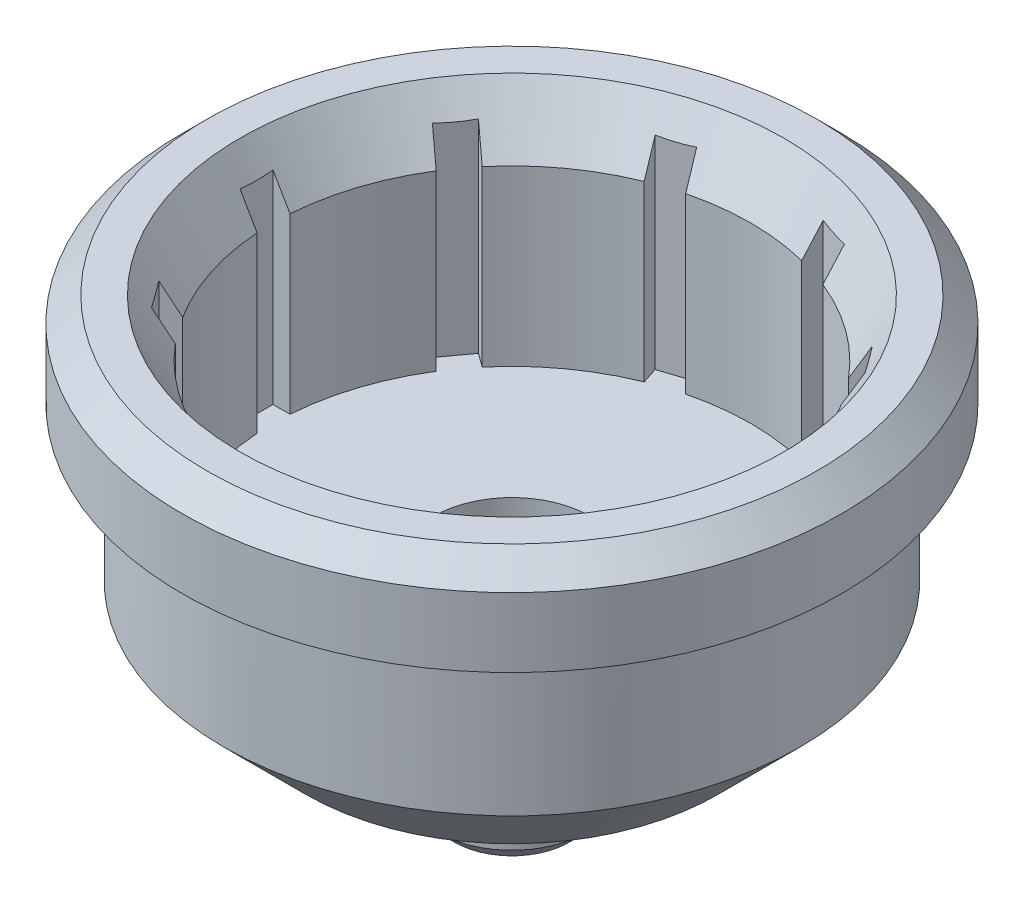
from build123d import *

# Parameters (mm, degrees)
CHAMFER1_SIZE      = 2
CHAMFER1_SIZE2     = 3.464101615
CHAMFER2_SIZE      = 1.5
SKETCH2_W          = 31
SKETCH2_H          = 2
CUT_EXTRUDE1_DEPTH = 15
CIRPATTERN1_COUNT  = 10
CHAMFER3_SIZE      = 5
CHAMFER4_SIZE      = 1


with BuildPart() as part:
    # Sketch1 → Revolve1 (revolve)
    with BuildSketch(Plane.XY):
        Polygon((-2.5, 0), (-2.5, 9), (-4.75, 9), (-4.75, 13), (-14.5, 13), (-14.5, 27), (-20, 27), (-20, 21.3), (-17.5, 21.3), (-17.5, 7), (-6.5, 7), (-6.5, 6), (-4.5, 6), (-4.5, 0), align=None)
    revolve(axis=Axis((0, 0, 0), (0, 1, 0)))

    # Chamfer1
    chamfer1_edges = [part.edges().sort_by_distance(p)[0] for p in [
        (14.5, 27, 0),
    ]]
    chamfer1_side = [part.faces().sort_by_distance(p)[0] for p in [
        (15.065685425, 27, 0),
    ]]
    chamfer(chamfer1_edges, length=CHAMFER1_SIZE, length2=CHAMFER1_SIZE2, reference=chamfer1_side[0])

    # Chamfer2
    chamfer2_edges = [part.edges().sort_by_distance(p)[0] for p in [
        (20, 27, 0),
    ]]
    chamfer(chamfer2_edges, length=CHAMFER2_SIZE)

    # Sketch2 → Cut-Extrude1 (cut, through all)
    with BuildSketch(Plane(origin=(0, 13, 0), x_dir=(1, 0, 0), z_dir=(0, 1, 0))):
        Rectangle(SKETCH2_W, SKETCH2_H)
    cut_extrude1 = extrude(amount=CUT_EXTRUDE1_DEPTH, mode=Mode.SUBTRACT)

    # CirPattern1: Cut-Extrude1 ×10 about axis
    cirpattern1_axis = Axis((0, 0, 0), (0, 1, 0))
    for i in range(1, CIRPATTERN1_COUNT):
        add(cut_extrude1.rotate(cirpattern1_axis, i * 360 / CIRPATTERN1_COUNT), mode=Mode.SUBTRACT)

    # Chamfer3
    chamfer3_edges = [part.edges().sort_by_distance(p)[0] for p in [
        (17.5, 7, 0),
    ]]
    chamfer(chamfer3_edges, length=CHAMFER3_SIZE)

    # Chamfer4
    chamfer4_edges = [part.edges().sort_by_distance(p)[0] for p in [
        (4.5, 0, 0),
    ]]
    chamfer(chamfer4_edges, length=CHAMFER4_SIZE)


solid = part.part
